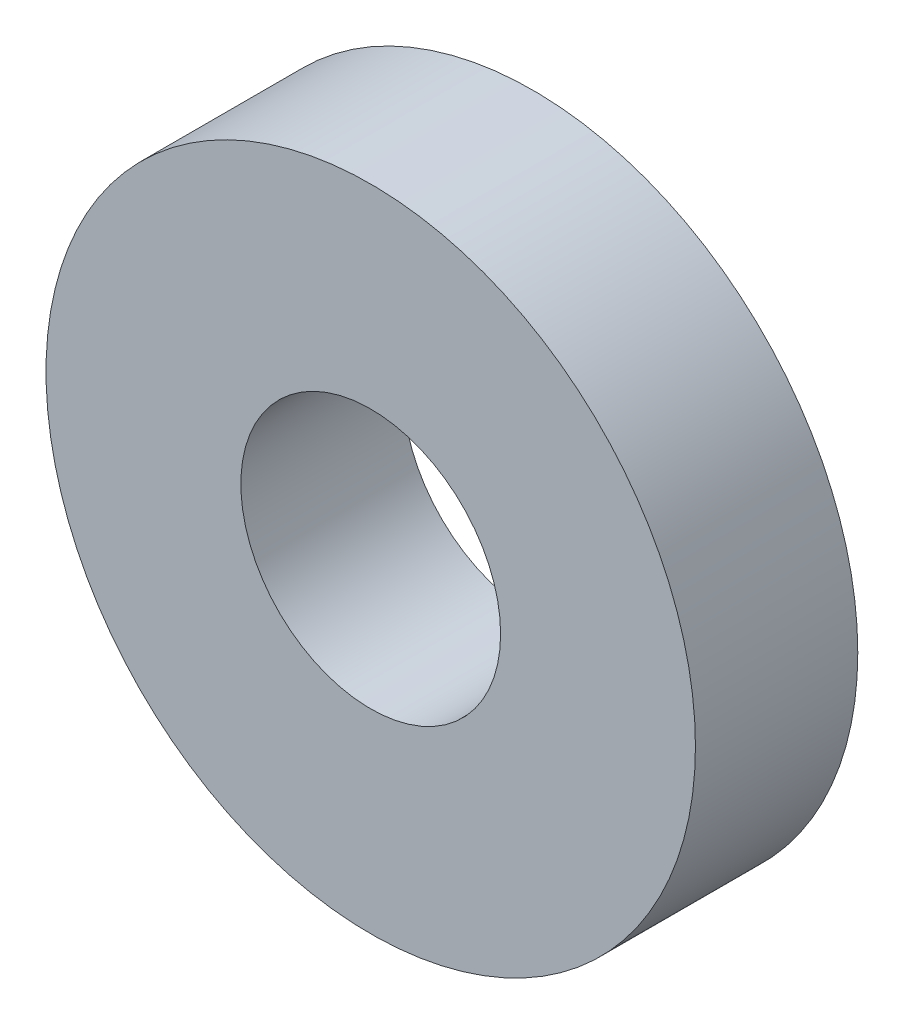
from build123d import *

# Parameters (mm, degrees)
SKETCH1_R           = 5
SKETCH1_R_2         = 2
BOSS_EXTRUDE1_DEPTH = 2.5


with BuildPart() as part:
    # Sketch1 → Boss-Extrude1 (new body)
    with BuildSketch(Plane.XY):
        Circle(SKETCH1_R)
        Circle(SKETCH1_R_2, mode=Mode.SUBTRACT)
    extrude(amount=BOSS_EXTRUDE1_DEPTH)


solid = part.part
